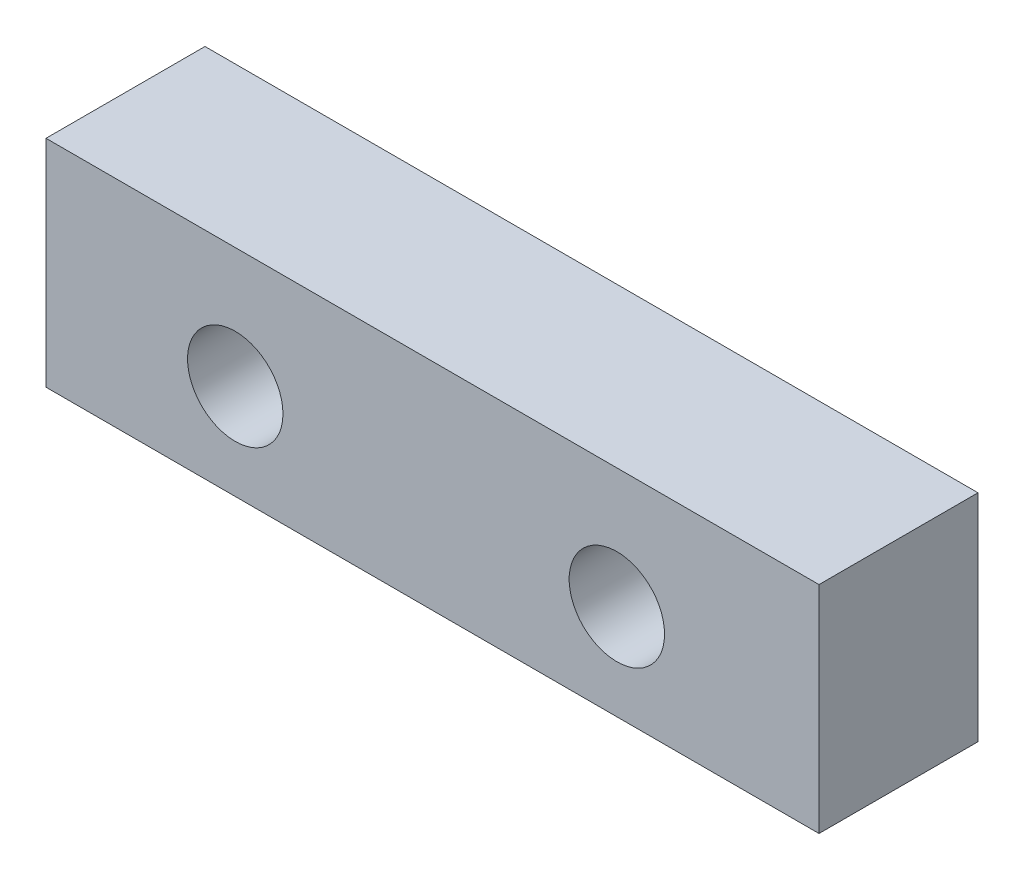
from build123d import *

# Parameters (mm, degrees)
SKETCH1_W           = 24.30840356
SKETCH1_H           = 6.77989487
SKETCH1_R           = 1.5
SKETCH1_R_2         = 1.500000007
BOSS_EXTRUDE1_DEPTH = 5


with BuildPart() as part:
    # Sketch1 → Boss-Extrude1 (new body)
    with BuildSketch(Plane.XY):
        with Locations((4.547490462, -1.322906316)):
            Rectangle(SKETCH1_W, SKETCH1_H)
        with Locations((-1.655334115, -1.71285375)):
            Circle(SKETCH1_R, mode=Mode.SUBTRACT)
        with Locations((10.344665883, -1.712853758)):
            Circle(SKETCH1_R_2, mode=Mode.SUBTRACT)
    extrude(amount=BOSS_EXTRUDE1_DEPTH)


solid = part.part
